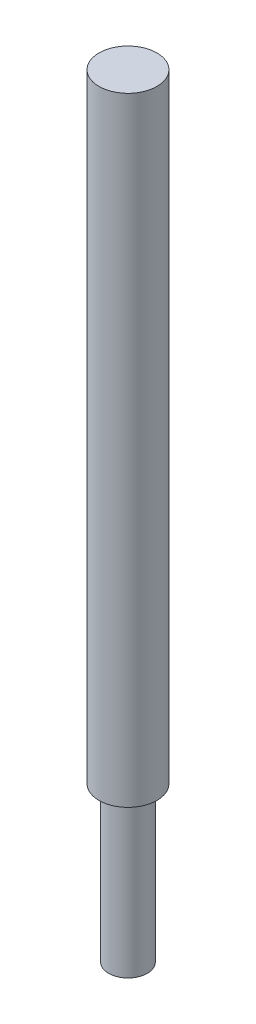
from build123d import *

# Parameters (mm, degrees)
SKETCH1_R           = 3.175
BOSS_EXTRUDE1_DEPTH = 25.4
SKETCH2_R           = 4.7625
BOSS_EXTRUDE2_DEPTH = 101.6


with BuildPart() as part:
    # Sketch1 → Boss-Extrude1 (new body)
    with BuildSketch(Plane(origin=(0, 0, 0), x_dir=(1, 0, 0), z_dir=(0, 1, 0))):
        Circle(SKETCH1_R)
    extrude(amount=BOSS_EXTRUDE1_DEPTH)

    # Sketch2 → Boss-Extrude2 (add)
    with BuildSketch(Plane(origin=(0, 25.4, 0), x_dir=(1, 0, 0), z_dir=(0, 1, 0))):
        Circle(SKETCH2_R)
    extrude(amount=BOSS_EXTRUDE2_DEPTH)


solid = part.part
